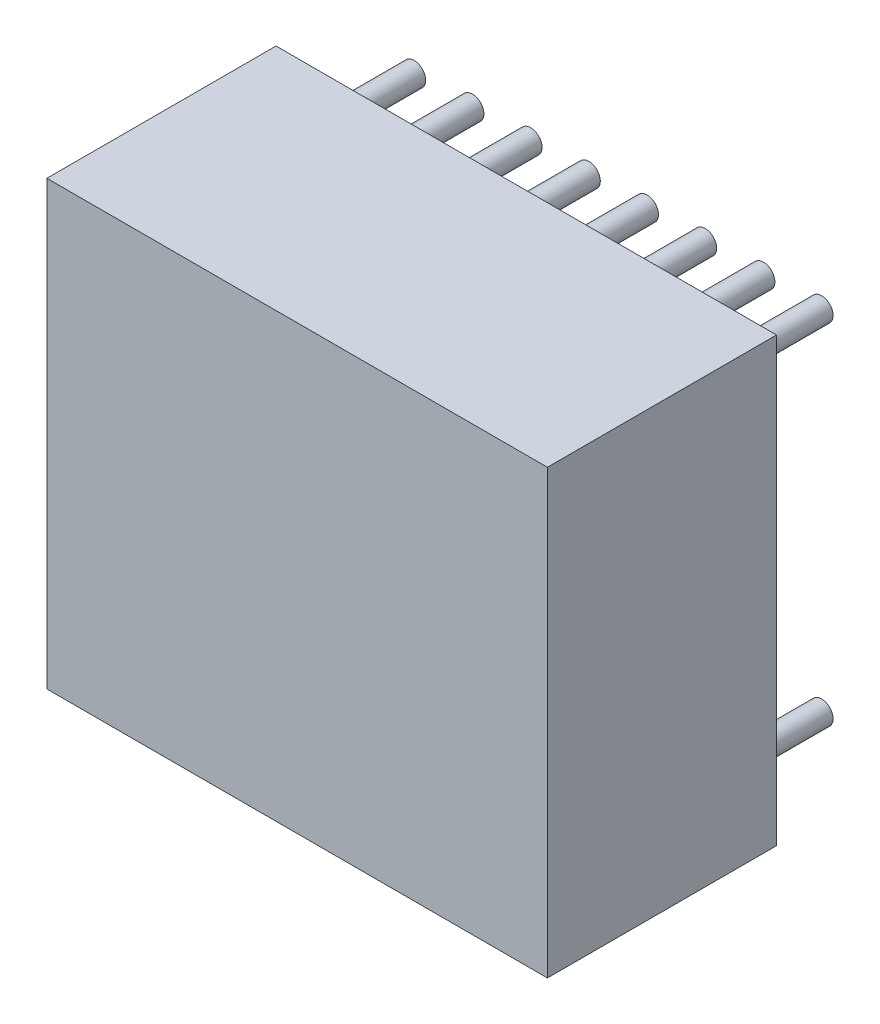
from build123d import *

# Parameters (mm, degrees)
SKETCH1_W               = 10.922
SKETCH1_H               = 9.652
COMPONENT_OUTLINE_DEPTH = 5
SKETCH2_R               = 0.25
EXTRUDE_1_DEPTH         = 2
SKETCH3_R               = 0.25
EXTRUDE_2_DEPTH         = 2
SKETCH4_R               = 0.25
EXTRUDE_3_DEPTH         = 2
SKETCH5_R               = 0.25
EXTRUDE_4_DEPTH         = 2
SKETCH6_R               = 0.25
EXTRUDE_5_DEPTH         = 2
SKETCH7_R               = 0.25
EXTRUDE_6_DEPTH         = 2
SKETCH8_R               = 0.25
EXTRUDE_7_DEPTH         = 2
SKETCH9_R               = 0.25
EXTRUDE_8_DEPTH         = 2
SKETCH10_R              = 0.25
EXTRUDE_9_DEPTH         = 2
SKETCH11_R              = 0.25
EXTRUDE_10_DEPTH        = 2
SKETCH12_R              = 0.25
EXTRUDE_11_DEPTH        = 2
SKETCH13_R              = 0.25
EXTRUDE_12_DEPTH        = 2
SKETCH14_R              = 0.25
EXTRUDE_13_DEPTH        = 2
SKETCH15_R              = 0.25
EXTRUDE_14_DEPTH        = 2
SKETCH16_R              = 0.25
EXTRUDE_15_DEPTH        = 2
SKETCH17_R              = 0.25
EXTRUDE_16_DEPTH        = 2


with BuildPart() as part:
    # Sketch1 → Component_Outline (new body)
    with BuildSketch(Plane.XY):
        with Locations((4.445, 3.81)):
            Rectangle(SKETCH1_W, SKETCH1_H)
    extrude(amount=COMPONENT_OUTLINE_DEPTH)


with BuildPart() as body_2:
    # Sketch2 → Extrude 1 (new body)
    with BuildSketch(Plane.XY):
        Circle(SKETCH2_R)
    extrude(amount=-EXTRUDE_1_DEPTH)


with BuildPart() as body_3:
    # Sketch3 → Extrude 2 (new body)
    with BuildSketch(Plane.XY):
        with Locations((1.27, 0)):
            Circle(SKETCH3_R)
    extrude(amount=-EXTRUDE_2_DEPTH)


with BuildPart() as body_4:
    # Sketch4 → Extrude 3 (new body)
    with BuildSketch(Plane.XY):
        with Locations((2.54, 0)):
            Circle(SKETCH4_R)
    extrude(amount=-EXTRUDE_3_DEPTH)


with BuildPart() as body_5:
    # Sketch5 → Extrude 4 (new body)
    with BuildSketch(Plane.XY):
        with Locations((3.81, 0)):
            Circle(SKETCH5_R)
    extrude(amount=-EXTRUDE_4_DEPTH)


with BuildPart() as body_6:
    # Sketch6 → Extrude 5 (new body)
    with BuildSketch(Plane.XY):
        with Locations((5.08, 0)):
            Circle(SKETCH6_R)
    extrude(amount=-EXTRUDE_5_DEPTH)


with BuildPart() as body_7:
    # Sketch7 → Extrude 6 (new body)
    with BuildSketch(Plane.XY):
        with Locations((6.35, 0)):
            Circle(SKETCH7_R)
    extrude(amount=-EXTRUDE_6_DEPTH)


with BuildPart() as body_8:
    # Sketch8 → Extrude 7 (new body)
    with BuildSketch(Plane.XY):
        with Locations((7.62, 0)):
            Circle(SKETCH8_R)
    extrude(amount=-EXTRUDE_7_DEPTH)


with BuildPart() as body_9:
    # Sketch9 → Extrude 8 (new body)
    with BuildSketch(Plane.XY):
        with Locations((8.89, 0)):
            Circle(SKETCH9_R)
    extrude(amount=-EXTRUDE_8_DEPTH)


with BuildPart() as body_10:
    # Sketch10 → Extrude 9 (new body)
    with BuildSketch(Plane.XY):
        with Locations((8.89, 7.62)):
            Circle(SKETCH10_R)
    extrude(amount=-EXTRUDE_9_DEPTH)


with BuildPart() as body_11:
    # Sketch11 → Extrude 10 (new body)
    with BuildSketch(Plane.XY):
        with Locations((7.62, 7.62)):
            Circle(SKETCH11_R)
    extrude(amount=-EXTRUDE_10_DEPTH)


with BuildPart() as body_12:
    # Sketch12 → Extrude 11 (new body)
    with BuildSketch(Plane.XY):
        with Locations((6.35, 7.62)):
            Circle(SKETCH12_R)
    extrude(amount=-EXTRUDE_11_DEPTH)


with BuildPart() as body_13:
    # Sketch13 → Extrude 12 (new body)
    with BuildSketch(Plane.XY):
        with Locations((5.08, 7.62)):
            Circle(SKETCH13_R)
    extrude(amount=-EXTRUDE_12_DEPTH)


with BuildPart() as body_14:
    # Sketch14 → Extrude 13 (new body)
    with BuildSketch(Plane.XY):
        with Locations((3.81, 7.62)):
            Circle(SKETCH14_R)
    extrude(amount=-EXTRUDE_13_DEPTH)


with BuildPart() as body_15:
    # Sketch15 → Extrude 14 (new body)
    with BuildSketch(Plane.XY):
        with Locations((2.54, 7.62)):
            Circle(SKETCH15_R)
    extrude(amount=-EXTRUDE_14_DEPTH)


with BuildPart() as body_16:
    # Sketch16 → Extrude 15 (new body)
    with BuildSketch(Plane.XY):
        with Locations((1.27, 7.62)):
            Circle(SKETCH16_R)
    extrude(amount=-EXTRUDE_15_DEPTH)


with BuildPart() as body_17:
    # Sketch17 → Extrude 16 (new body)
    with BuildSketch(Plane.XY):
        with Locations((0, 7.62)):
            Circle(SKETCH17_R)
    extrude(amount=-EXTRUDE_16_DEPTH)


solid = Compound([part.part, body_2.part, body_3.part, body_4.part, body_5.part, body_6.part, body_7.part, body_8.part, body_9.part, body_10.part, body_11.part, body_12.part, body_13.part, body_14.part, body_15.part, body_16.part, body_17.part])
